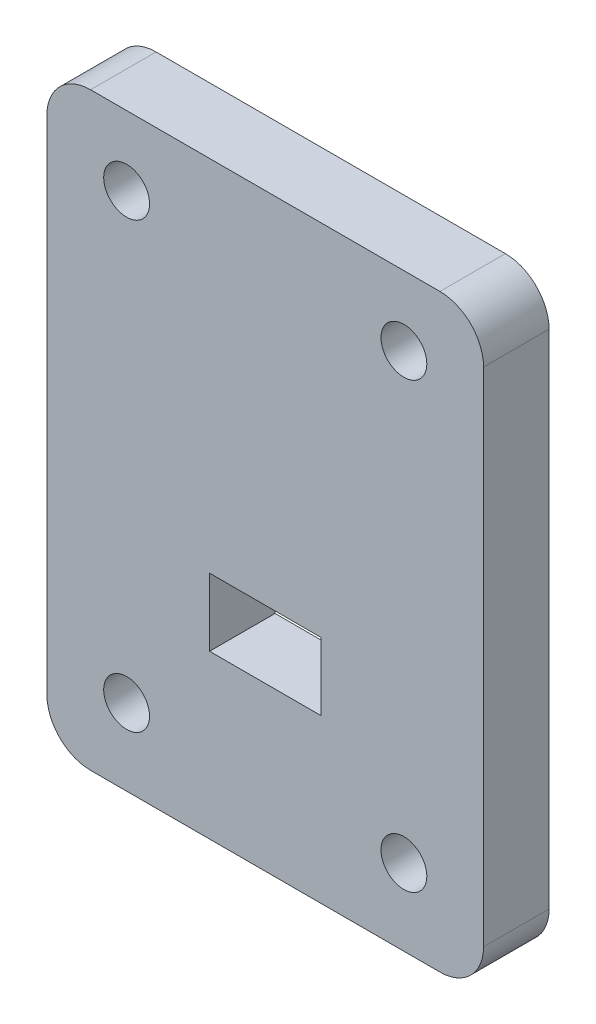
from build123d import *

# Parameters (mm, degrees)
CROQUIS1_W              = 20
CROQUIS1_H              = 27
SALIENTE_EXTRUIR1_DEPTH = 3
CROQUIS2_W              = 5.1
CROQUIS2_H              = 3.1
CORTAR_EXTRUIR1_DEPTH   = 10
CROQUIS3_R              = 1.05
CORTAR_EXTRUIR2_DEPTH   = 10
REDONDEO1_R             = 2


with BuildPart() as part:
    # Croquis1 → Saliente-Extruir1 (new body)
    with BuildSketch(Plane.XY):
        Rectangle(CROQUIS1_W, CROQUIS1_H)
    extrude(amount=SALIENTE_EXTRUIR1_DEPTH)

    # Croquis2 → Cortar-Extruir1 (cut)
    with BuildSketch(Plane.XY.offset(3)):
        with Locations((0, -4.5)):
            Rectangle(CROQUIS2_W, CROQUIS2_H)
    extrude(amount=-CORTAR_EXTRUIR1_DEPTH, mode=Mode.SUBTRACT)

    # Croquis3 → Cortar-Extruir2 (cut)
    with BuildSketch(Plane.XY.offset(3)):
        with Locations((-6.35, 10.32)):
            Circle(CROQUIS3_R)
        with Locations((6.35, 10.32)):
            Circle(CROQUIS3_R)
        with Locations((6.35, -10)):
            Circle(CROQUIS3_R)
        with Locations((-6.35, -10)):
            Circle(CROQUIS3_R)
    extrude(amount=-CORTAR_EXTRUIR2_DEPTH, mode=Mode.SUBTRACT)

    # Redondeo1
    redondeo1_edges = [part.edges().sort_by_distance(p)[0] for p in [
        (10, -13.5, 1.5),
        (-10, -13.5, 1.5),
        (-10, 13.5, 1.5),
        (10, 13.5, 1.5),
    ]]
    fillet(redondeo1_edges, radius=REDONDEO1_R)


solid = part.part
